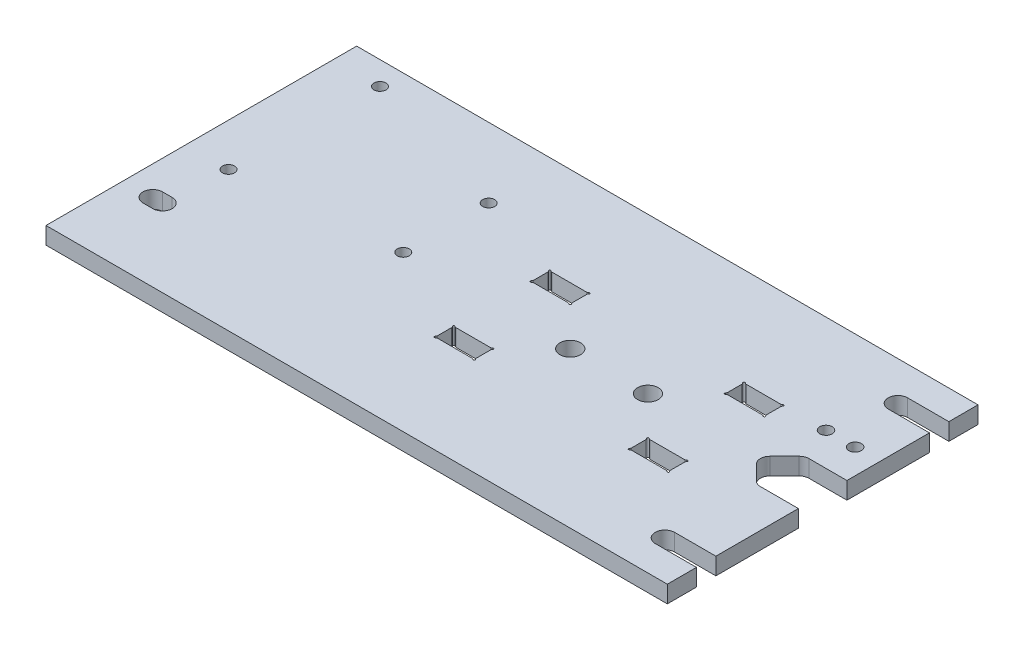
from build123d import *

# Parameters (mm, degrees)
BOSS_EXTRUDE1_DEPTH             = 5.588
F_1_4_CLEARANCE_HOLE1_D         = 6.35
F_1_4_CLEARANCE_HOLE1_DEPTH     = 5.588
CUT_EXTRUDE1_DEPTH              = 5.588
CUT_EXTRUDE2_REACH              = 7.588
F_4_CLEARANCE_HOLE1_D           = 3.937
F_4_CLEARANCE_HOLE1_DEPTH       = 5.588
CUT_EXTRUDE3_DEPTH              = 5.588
FILLET1_R                       = 0.635
FILLET1_OF_MIRROR2_R            = 0.635
F_10_CLEARANCE_HOLE1_D          = 6.7818
F_10_CLEARANCE_HOLE1_DEPTH      = 5.588
TAP_DRILL_FOR_4_HELICOIL1_D     = 4.064
TAP_DRILL_FOR_4_HELICOIL1_DEPTH = 6.35
TAP_DRILL_FOR_4_HELICOIL1_TIP   = 1.220948778


with BuildPart() as part:
    # Sketch1 → Boss-Extrude1 (new body)
    with BuildSketch(Plane(origin=(0, 0, 0), x_dir=(1, 0, 0), z_dir=(0, 1, 0))):
        with BuildLine():
            Line((-101.6, 50.8), (101.6, 50.8))
            Line((101.6, 50.8), (101.6, 7.9375))
            Line((101.6, 7.9375), (89.172371939, 7.9375))
            ThreePointArc((89.172371939, 7.9375), (87.957352042, 7.695817516), (86.927307909, 7.00756403))
            Line((86.927307909, 7.00756403), (82.164807909, 2.24506403))
            ThreePointArc((82.164807909, 2.24506403), (81.234871939, 0), (82.164807909, -2.24506403))
            Line((82.164807909, -2.24506403), (86.927307909, -7.00756403))
            ThreePointArc((86.927307909, -7.00756403), (87.957352042, -7.695817516), (89.172371939, -7.9375))
            Line((89.172371939, -7.9375), (101.6, -7.9375))
            Line((101.6, -7.9375), (101.6, -50.8))
            Line((101.6, -50.8), (-101.6, -50.8))
            Line((-101.6, -50.8), (-101.6, 50.8))
        make_face()
    extrude(amount=BOSS_EXTRUDE1_DEPTH)

    # 1/4 Clearance Hole1
    with Locations(Plane(origin=(0, 5.588, 0), x_dir=(-1, 0, 0), z_dir=(0, 1, 0))):
        with Locations((-88.10625, 38.1), (-88.10625, -38.1), (88.9, 25.4)):
            Hole(F_1_4_CLEARANCE_HOLE1_D / 2, depth=F_1_4_CLEARANCE_HOLE1_DEPTH)

    # Sketch4 → Cut-Extrude1 (cut)
    with BuildSketch(Plane(origin=(0, 5.588, 0), x_dir=(1, 0, 0), z_dir=(0, 1, 0))):
        with BuildLine():
            Line((88.10625, 41.275), (101.6, 41.275))
            Line((101.6, 41.275), (101.6, 34.925))
            Line((101.6, 34.925), (88.10625, 34.925))
            ThreePointArc((88.10625, 34.925), (84.93125, 38.1), (88.10625, 41.275))
        make_face()
    cut_extrude1 = extrude(amount=-CUT_EXTRUDE1_DEPTH, mode=Mode.SUBTRACT)

    # Mirror1: Cut-Extrude1 across plane
    add(cut_extrude1.mirror(Plane.XY), mode=Mode.SUBTRACT)

    # Sketch5 → Cut-Extrude2 (cut, up to next)
    with BuildSketch(Plane(origin=(0, 5.588, 0), x_dir=(1, 0, 0), z_dir=(0, 1, 0)), mode=Mode.PRIVATE) as cut_extrude2_sk1:
        with BuildLine():
            Line((-92.075, -22.225), (-88.9, -22.225))
            ThreePointArc((-88.9, -22.225), (-85.725, -25.4), (-88.9, -28.575))
            Line((-88.9, -28.575), (-92.075, -28.575))
            ThreePointArc((-92.075, -28.575), (-95.25, -25.4), (-92.075, -22.225))
        make_face()
    cut_extrude2_tool1 = extrude(cut_extrude2_sk1.sketch, amount=-CUT_EXTRUDE2_REACH, mode=Mode.PRIVATE) & part.part
    add(cut_extrude2_tool1.solids().sort_by_distance((-90.4875, 5.588, 25.4))[0], mode=Mode.SUBTRACT)

    # #4 Clearance Hole1
    with Locations(Plane(origin=(0, 5.588, 0), x_dir=(-1, 0, 0), z_dir=(0, 1, 0))):
        with Locations((86.36, -43.18), (35.56, -27.94), (35.56, 0), (87.63, 5.08)):
            Hole(F_4_CLEARANCE_HOLE1_D / 2, depth=F_4_CLEARANCE_HOLE1_DEPTH)

    # Sketch9 → Cut-Extrude3 (cut)
    with BuildSketch(Plane(origin=(0, 5.588, 0), x_dir=(1, 0, 0), z_dir=(0, 1, 0))):
        with BuildLine():
            Line((-6.0325, 18.7198), (6.0325, 18.7198))
            ThreePointArc((6.0325, 18.7198), (6.574506403, 18.944306403), (6.35, 18.4023))
            Line((6.35, 18.4023), (6.35, 13.0175))
            ThreePointArc((6.35, 13.0175), (6.574506403, 12.475493597), (6.0325, 12.7))
            Line((6.0325, 12.7), (-6.0325, 12.7))
            ThreePointArc((-6.0325, 12.7), (-6.574506403, 12.475493597), (-6.35, 13.0175))
            Line((-6.35, 13.0175), (-6.35, 18.4023))
            ThreePointArc((-6.35, 18.4023), (-6.574506403, 18.944306403), (-6.0325, 18.7198))
        make_face()
        with BuildLine():
            Line((57.15, 18.4023), (57.15, 13.0175))
            ThreePointArc((57.15, 13.0175), (56.925493597, 12.475493597), (57.4675, 12.7))
            Line((57.4675, 12.7), (69.5325, 12.7))
            ThreePointArc((69.5325, 12.7), (70.074506403, 12.475493597), (69.85, 13.0175))
            Line((69.85, 13.0175), (69.85, 18.4023))
            ThreePointArc((69.85, 18.4023), (70.074506403, 18.944306403), (69.5325, 18.7198))
            Line((69.5325, 18.7198), (57.4675, 18.7198))
            ThreePointArc((57.4675, 18.7198), (56.925493597, 18.944306403), (57.15, 18.4023))
        make_face()
    cut_extrude3 = extrude(amount=-CUT_EXTRUDE3_DEPTH, mode=Mode.SUBTRACT)

    # Fillet1
    fillet1_edges = [part.edges().sort_by_distance(p)[0] for p in [
        (-6.35, 2.794, -18.4023),
        (-6.0325, 2.794, -18.7198),
        (6.0325, 2.794, -18.7198),
        (6.35, 2.794, -18.4023),
        (6.35, 2.794, -13.0175),
        (6.0325, 2.794, -12.7),
        (-6.0325, 2.794, -12.7),
        (-6.35, 2.794, -13.0175),
        (69.85, 2.794, -13.0175),
        (69.5325, 2.794, -12.7),
        (57.4675, 2.794, -12.7),
        (57.15, 2.794, -13.0175),
        (57.15, 2.794, -18.4023),
        (57.4675, 2.794, -18.7198),
        (69.5325, 2.794, -18.7198),
        (69.85, 2.794, -18.4023),
    ]]
    fillet(fillet1_edges, radius=FILLET1_R)

    # Mirror2: Cut-Extrude3 across plane
    add(cut_extrude3.mirror(Plane.XY), mode=Mode.SUBTRACT)

    # Fillet1 of Mirror2
    fillet1_of_mirror2_edges = [part.edges().sort_by_distance(p)[0] for p in [
        (-6.35, 2.794, 18.4023),
        (-6.0325, 2.794, 18.7198),
        (6.0325, 2.794, 18.7198),
        (6.35, 2.794, 18.4023),
        (6.35, 2.794, 13.0175),
        (6.0325, 2.794, 12.7),
        (-6.0325, 2.794, 12.7),
        (-6.35, 2.794, 13.0175),
        (69.85, 2.794, 13.0175),
        (69.5325, 2.794, 12.7),
        (57.4675, 2.794, 12.7),
        (57.15, 2.794, 13.0175),
        (57.15, 2.794, 18.4023),
        (57.4675, 2.794, 18.7198),
        (69.5325, 2.794, 18.7198),
        (69.85, 2.794, 18.4023),
    ]]
    fillet(fillet1_of_mirror2_edges, radius=FILLET1_OF_MIRROR2_R)

    # #10 Clearance Hole1
    with Locations(Plane(origin=(0, 5.588, 0), x_dir=(-1, 0, 0), z_dir=(0, 1, 0))):
        with Locations((-19.05, 0), (-44.45, 0)):
            Hole(F_10_CLEARANCE_HOLE1_D / 2, depth=F_10_CLEARANCE_HOLE1_DEPTH)

    # Tap Drill for #4 Helicoil1
    with Locations(Plane(origin=(0, 5.588, 0), x_dir=(1, 0, 0), z_dir=(0, 1, 0))):
        with Locations((93.4847, 18.7325), (83.9597, 18.7325)):
            Hole(TAP_DRILL_FOR_4_HELICOIL1_D / 2, depth=TAP_DRILL_FOR_4_HELICOIL1_DEPTH)
            with Locations((0, 0, -(TAP_DRILL_FOR_4_HELICOIL1_DEPTH + TAP_DRILL_FOR_4_HELICOIL1_TIP / 2))):  # 118° drill point
                Cone(0, TAP_DRILL_FOR_4_HELICOIL1_D / 2, TAP_DRILL_FOR_4_HELICOIL1_TIP, mode=Mode.SUBTRACT)


solid = part.part
